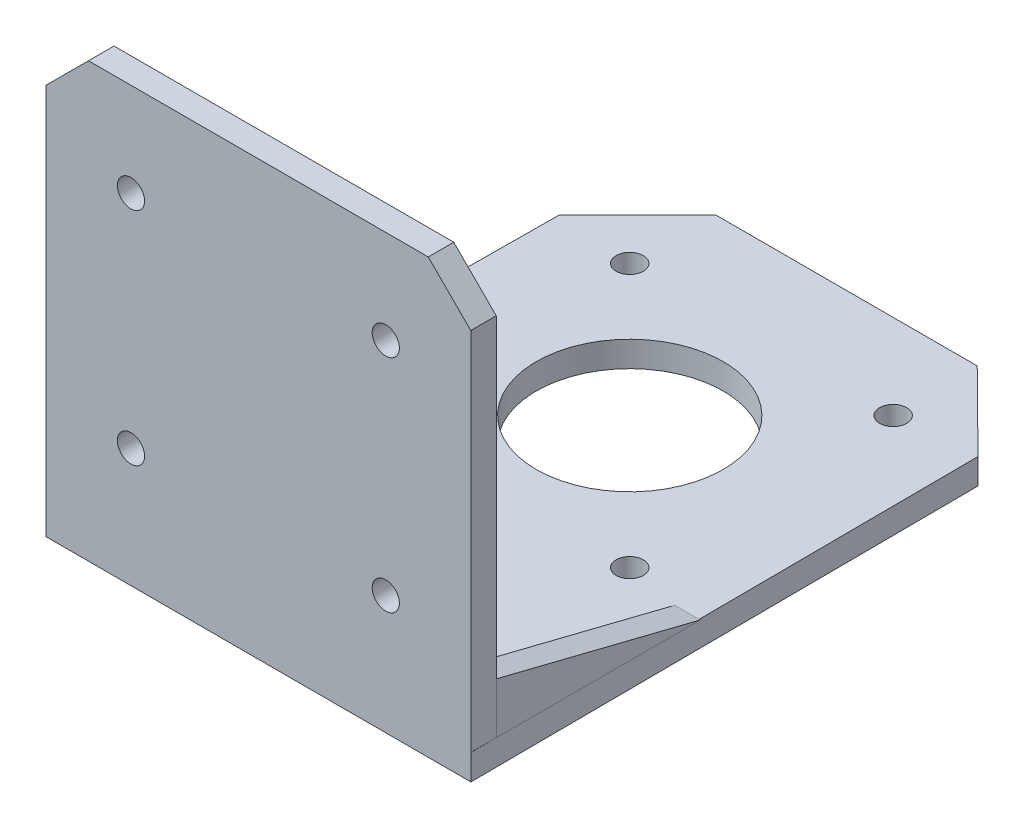
from build123d import *

# Parameters (mm, degrees)
SKETCH2_R                      = 11
SKETCH2_R_2                    = 1.6
BOSS_EXTRUDE1_DEPTH            = 3
SKETCH4_W                      = 49.983681894
SKETCH4_H                      = 3
BOSS_EXTRUDE2_DEPTH            = 48
CUT_EXTRUDE1_DEPTH             = 8
F_3_2_3_2_DIAMETER_HOLE1_D     = 3.2
F_3_2_3_2_DIAMETER_HOLE1_DEPTH = 3.2
F_3_2_3_2_DIAMETER_HOLE1_TIP   = 0.96137699
GUSSET1_THICKNESS              = 3
GUSSET2_THICKNESS              = 3


with BuildPart() as part:
    # Sketch2 → Boss-Extrude1 (new body)
    with BuildSketch(Plane(origin=(0, 0, 0), x_dir=(1, 0, 0), z_dir=(0, 1, 0))):
        Polygon((-0.281070854, -64.689517544), (-50.281070854, -64.689517544), (-49.863685081, -4.690081702), (-40.672742725, 4.500860654), (-9.889398982, 4.500860654), (-0.607432979, -4.689517544), align=None)
        with Locations(Location((-25.281070854, -21, 0), (0, 0, 270))):
            Circle(SKETCH2_R, mode=Mode.SUBTRACT)
        with Locations(Location((-40.781070854, -5.5, 0), (0, 0, 270))):
            Circle(SKETCH2_R_2, mode=Mode.SUBTRACT)
        with Locations(Location((-9.781070854, -5.5, 0), (0, 0, 270))):
            Circle(SKETCH2_R_2, mode=Mode.SUBTRACT)
        with Locations(Location((-40.781070854, -36.5, 0), (0, 0, 270))):
            Circle(SKETCH2_R_2, mode=Mode.SUBTRACT)
        with Locations(Location((-9.781070854, -36.5, 0), (0, 0, 270))):
            Circle(SKETCH2_R_2, mode=Mode.SUBTRACT)
    extrude(amount=BOSS_EXTRUDE1_DEPTH)

    # Sketch4 → Boss-Extrude2 (add)
    with BuildSketch(Plane(origin=(0, 3, 0), x_dir=(1, 0, 0), z_dir=(0, 1, 0))):
        with Locations((-25.289229907, -63.189517544)):
            Rectangle(SKETCH4_W, SKETCH4_H)
    extrude(amount=BOSS_EXTRUDE2_DEPTH)

    # Sketch5 → Cut-Extrude1 (cut)
    with BuildSketch(Plane(origin=(0, 0, 61.689517544), x_dir=(-1, 0, 0), z_dir=(0, 0, -1))):
        Polygon((0.29738896, 51), (0.29738896, 46), (5.29738896, 51), align=None)
        Polygon((50.281070854, 51), (45.281070854, 51), (50.281070854, 46), align=None)
    extrude(amount=-CUT_EXTRUDE1_DEPTH, mode=Mode.SUBTRACT)

    # Ø3.2 (3.2) Diameter Hole1
    with Locations(Plane(origin=(0, 0, 61.689517544), x_dir=(-1, 0, 0), z_dir=(0, 0, -1))):
        with Locations((10.29738896, 40), (40.281070854, 40), (40.281070854, 14), (10.29738896, 14)):
            Hole(F_3_2_3_2_DIAMETER_HOLE1_D / 2, depth=F_3_2_3_2_DIAMETER_HOLE1_DEPTH)
            with Locations((0, 0, -(F_3_2_3_2_DIAMETER_HOLE1_DEPTH + F_3_2_3_2_DIAMETER_HOLE1_TIP / 2))):  # 118° drill point
                Cone(0, F_3_2_3_2_DIAMETER_HOLE1_D / 2, F_3_2_3_2_DIAMETER_HOLE1_TIP, mode=Mode.SUBTRACT)


with BuildPart() as body_2:
    # Gusset1: a gusset: a plate 3.0 thick in the corner of two members, its outline drawn in place
    gusset1_outline = Wire([Line((-47.260201369, 3, 61.689517544), (-47.260201369, 3, 37.689517544)), Line((-47.260201369, 3, 37.689517544), (-47.260201369, 9, 61.689517544)), Line((-47.260201369, 9, 61.689517544), (-47.260201369, 3, 61.689517544))])
    add(extrude(Face(gusset1_outline), amount=GUSSET1_THICKNESS, dir=(-1, 0, 0)))


with BuildPart() as body_3:
    # Gusset2: a gusset: a plate 3.0 thick in the corner of two members, its outline drawn in place
    gusset2_outline = Wire([Line((-3.29738896, 3, 61.689517544), (-3.29738896, 9, 61.689517544)), Line((-3.29738896, 9, 61.689517544), (-3.29738896, 3, 37.689517544)), Line((-3.29738896, 3, 37.689517544), (-3.29738896, 3, 61.689517544))])
    add(extrude(Face(gusset2_outline), amount=GUSSET2_THICKNESS, dir=(1, 0, 0)))


solid = Compound([part.part, body_2.part, body_3.part])
